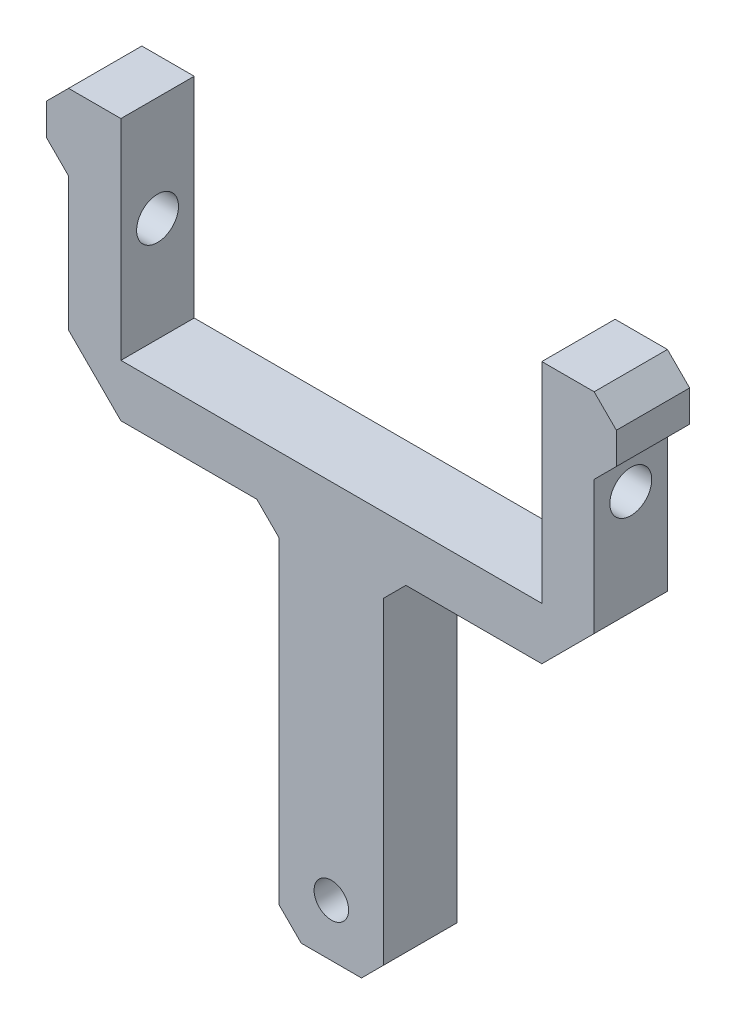
from build123d import *

# Parameters (mm, degrees)
CROQUIS1_R              = 1.65
SALIENTE_EXTRUIR1_DEPTH = 7
CORTAR_EXTRUIR1_DEPTH   = 8
CROQUIS3_R              = 2
CORTAR_EXTRUIR3_DEPTH   = 53.321320344
CROQUIS4_R              = 3.75
CORTAR_EXTRUIR4_DEPTH   = 3.121320344
CROQUIS5_R              = 3.75
CORTAR_EXTRUIR5_DEPTH   = 3.121320344


with BuildPart() as part:
    # Croquis1 → Saliente-Extruir1 (new body)
    with BuildSketch(Plane.XY):
        Polygon((-5, 27.478679656), (-5, -5), (5, -5), (5, 27.478679656), (7.121320344, 29.6), (20.102640687, 29.6), (25.1, 34.597359313), (25.1, 47.357359313), (27.221320344, 49.478679656), (27.221320344, 52.478679656), (25.1, 54.6), (20.1, 54.6), (20.1, 34.6), (-20.1, 34.6), (-20.1, 54.6), (-25.1, 54.6), (-27.221320344, 52.478679656), (-27.221320344, 49.478679656), (-25.1, 47.357359313), (-25.1, 34.597359313), (-20.102640687, 29.6), (-7.121320344, 29.6), align=None)
        Circle(CROQUIS1_R, mode=Mode.SUBTRACT)
    extrude(amount=SALIENTE_EXTRUIR1_DEPTH)

    # Croquis2 → Cortar-Extruir1 (cut, through all)
    with BuildSketch(Plane(origin=(0, 0, 0), x_dir=(-1, 0, 0), z_dir=(0, 0, -1))):
        Polygon((-5, -5), (-2.878679656, -5), (-5, -2.878679656), align=None)
        Polygon((2.878679656, -5), (5, -2.878679656), (5, -5), align=None)
    extrude(amount=-CORTAR_EXTRUIR1_DEPTH, mode=Mode.SUBTRACT)

    # Croquis3 → Cortar-Extruir3 (cut, through all)
    with BuildSketch(Plane.ZY.offset(25.1)):
        with Locations((3.5, 44.597359313)):
            Circle(CROQUIS3_R)
    extrude(amount=-CORTAR_EXTRUIR3_DEPTH, mode=Mode.SUBTRACT)

    # Croquis4 → Cortar-Extruir4 (cut, through all)
    with BuildSketch(Plane.ZY.offset(25.1)):
        with Locations((3.5, 44.597359313)):
            Circle(CROQUIS4_R)
    extrude(amount=CORTAR_EXTRUIR4_DEPTH, mode=Mode.SUBTRACT)

    # Croquis5 → Cortar-Extruir5 (cut, through all)
    with BuildSketch(Plane(origin=(25.1, 0, 0), x_dir=(0, 0, -1), z_dir=(1, 0, 0))):
        with Locations((-3.5, 44.597359313)):
            Circle(CROQUIS5_R)
    extrude(amount=CORTAR_EXTRUIR5_DEPTH, mode=Mode.SUBTRACT)


solid = part.part
